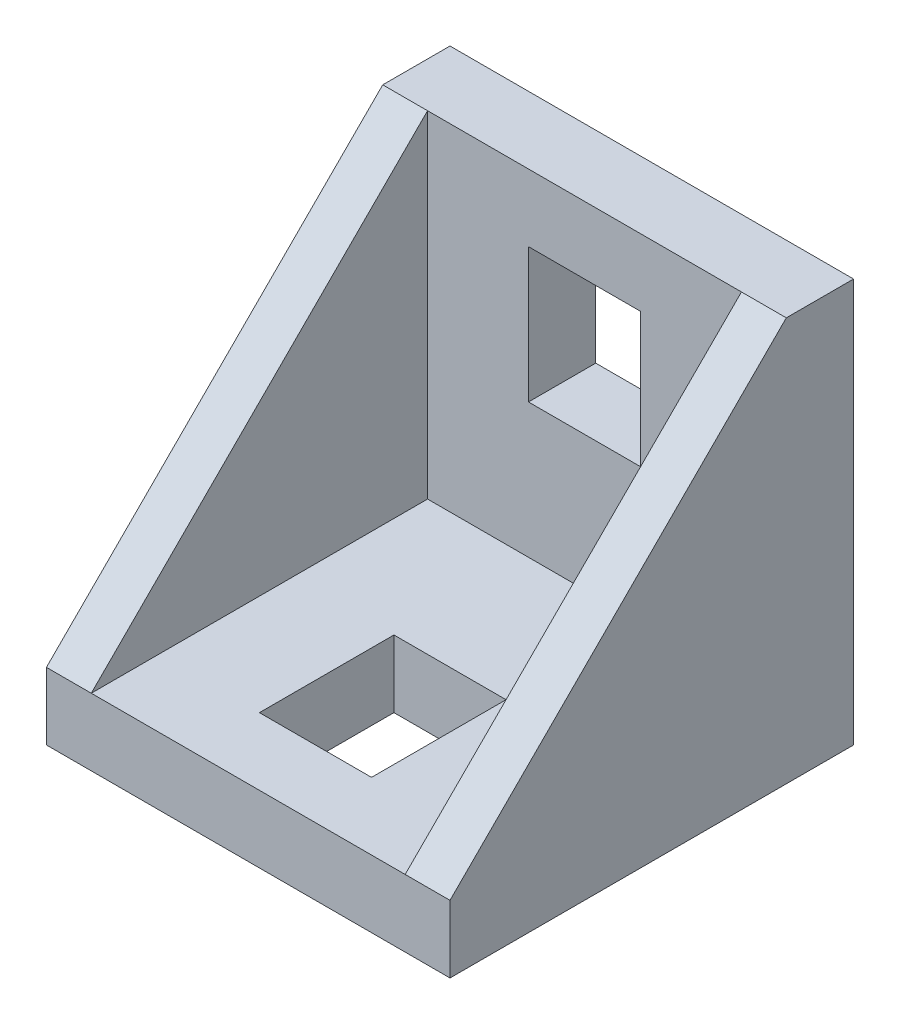
from build123d import *

# Parameters (mm, degrees)
SKETCH1_W          = 18
SKETCH1_H          = 18
EXTRUDE1_DEPTH     = 3
SKETCH2_W          = 18
SKETCH2_H          = 3
EXTRUDE2_DEPTH     = 15
EXTRUDE3_DEPTH     = 2
EXTRUDE4_DEPTH     = 2
CUT_EXTRUDE1_REACH = 5
SKETCH7_W          = 5
SKETCH7_H          = 6
CUT_EXTRUDE2_REACH = 5
SKETCH8_W          = 5
SKETCH8_H          = 6


with BuildPart() as part:
    # Sketch1 → Extrude1 (new body)
    with BuildSketch(Plane.XY):
        with Locations((9, 9)):
            Rectangle(SKETCH1_W, SKETCH1_H)
    extrude(amount=EXTRUDE1_DEPTH)

    # Sketch2 → Extrude2 (add)
    with BuildSketch(Plane.XY.offset(3)):
        with Locations((9, 1.5)):
            Rectangle(SKETCH2_W, SKETCH2_H)
    extrude(amount=EXTRUDE2_DEPTH)

    # Sketch5 → Extrude3 (add)
    with BuildSketch(Plane(origin=(18, 0, 0), x_dir=(0, 0, -1), z_dir=(1, 0, 0))):
        Polygon((-3, 18), (-18, 3), (-3, 3), align=None)
    extrude(amount=-EXTRUDE3_DEPTH)

    # Sketch6 → Extrude4 (add)
    with BuildSketch(Plane.ZY):
        Polygon((3, 18), (18, 3), (3, 3), align=None)
    extrude(amount=-EXTRUDE4_DEPTH)

    # Sketch7 → Cut-Extrude1 (cut, up to next)
    with BuildSketch(Plane(origin=(0, 3, 0), x_dir=(1, 0, 0), z_dir=(0, 1, 0)), mode=Mode.PRIVATE) as cut_extrude1_sk1:
        with Locations((9, -12)):
            Rectangle(SKETCH7_W, SKETCH7_H)
    cut_extrude1_tool1 = extrude(cut_extrude1_sk1.sketch, amount=-CUT_EXTRUDE1_REACH, mode=Mode.PRIVATE) & part.part
    add(cut_extrude1_tool1.solids().sort_by_distance((9, 3, 12))[0], mode=Mode.SUBTRACT)

    # Sketch8 → Cut-Extrude2 (cut, up to next)
    with BuildSketch(Plane(origin=(0, 0, 3), x_dir=(-1, 0, 0), z_dir=(0, 0, 1)), mode=Mode.PRIVATE) as cut_extrude2_sk1:
        with Locations((-9, -12)):
            Rectangle(SKETCH8_W, SKETCH8_H)
    cut_extrude2_tool1 = extrude(cut_extrude2_sk1.sketch, amount=-CUT_EXTRUDE2_REACH, mode=Mode.PRIVATE) & part.part
    add(cut_extrude2_tool1.solids().sort_by_distance((9, 12, 3))[0], mode=Mode.SUBTRACT)


solid = part.part
